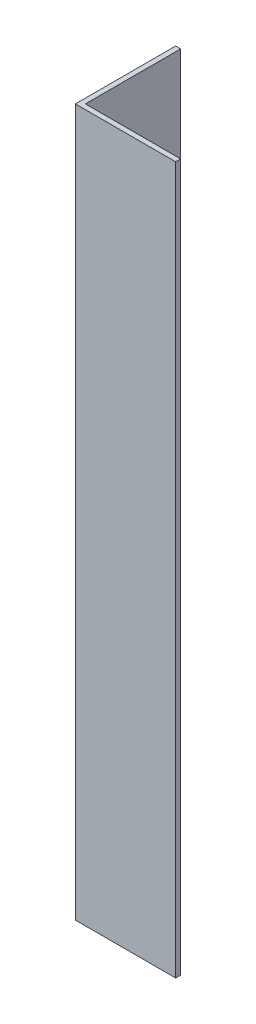
from build123d import *

# Parameters (mm, degrees)
EXTRUDE_1_DEPTH = 141


with BuildPart() as part:
    # Эскиз1 → Бобышка-Вытянуть1 (new body)
    with BuildSketch(Plane(origin=(0, 0, 0), x_dir=(1, 0, 0), z_dir=(0, 1, 0))):
        Polygon((0, 0), (0, 20), (1, 20), (1, 1), (20, 1), (20, 0), align=None)
    extrude(amount=EXTRUDE_1_DEPTH)


solid = part.part
